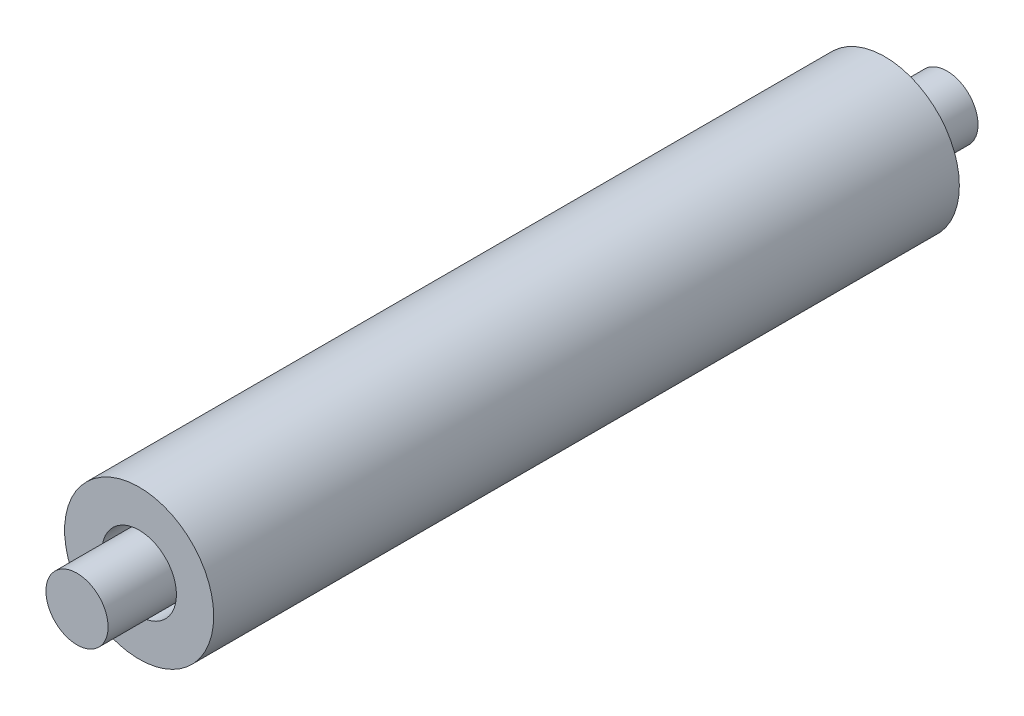
from build123d import *

# Parameters (mm, degrees)
SKETCH1_R         = 1.25
CENTRALAXIS_DEPTH = 17.5
SKETCH2_R         = 3
SKETCH2_R_2       = 1.5
ROLLINGAXIS_DEPTH = 15


with BuildPart() as part:
    # Sketch1 → CentralAxis (new body, symmetric)
    with BuildSketch(Plane.XY):
        Circle(SKETCH1_R)
    extrude(amount=CENTRALAXIS_DEPTH, both=True)


with BuildPart() as body_2:
    # Sketch2 → RollingAxis (new body, symmetric)
    with BuildSketch(Plane.XY):
        Circle(SKETCH2_R)
        Circle(SKETCH2_R_2, mode=Mode.SUBTRACT)
    extrude(amount=ROLLINGAXIS_DEPTH, both=True)


solid = Compound([part.part, body_2.part])
